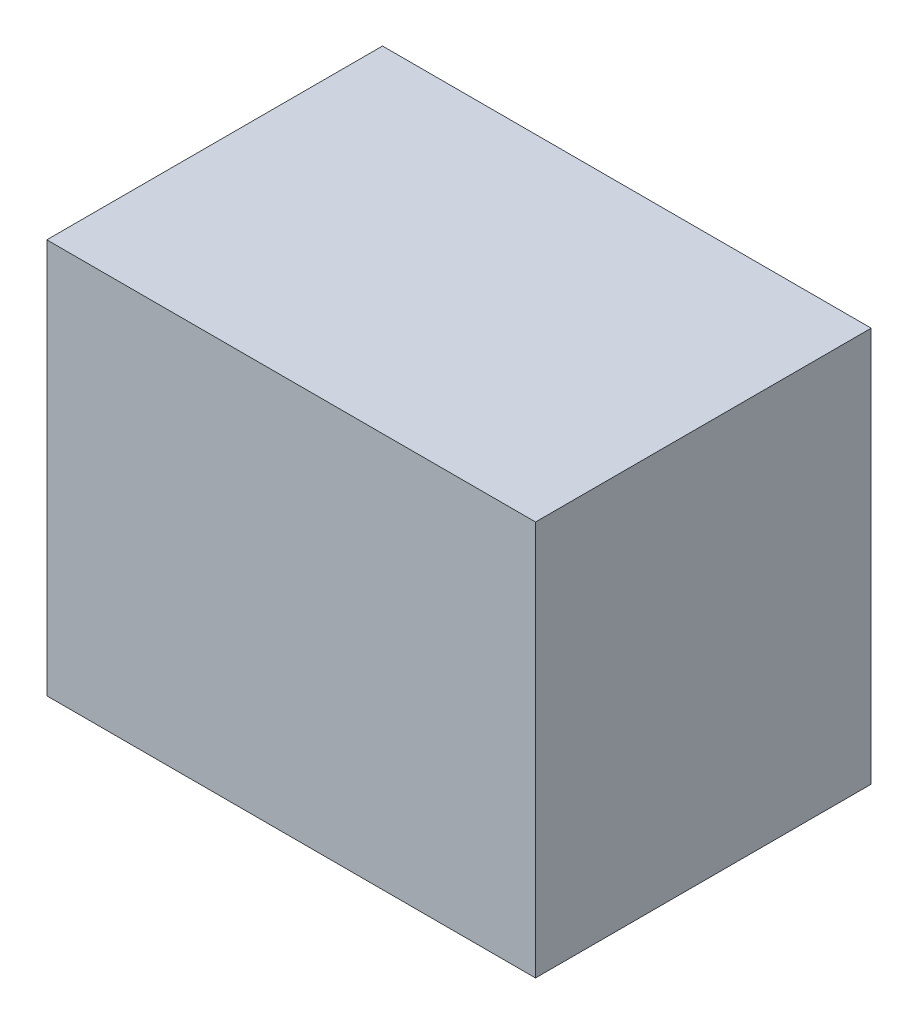
from build123d import *

# Parameters (mm, degrees)
SKETCH1_W           = 340
SKETCH1_H           = 400
BOSS_EXTRUDE1_DEPTH = 495


with BuildPart() as part:
    # Sketch1 → Boss-Extrude1 (new body)
    with BuildSketch(Plane(origin=(0, 0, 0), x_dir=(0, 0, -1), z_dir=(1, 0, 0))):
        Rectangle(SKETCH1_W, SKETCH1_H)
    extrude(amount=BOSS_EXTRUDE1_DEPTH)


solid = part.part
